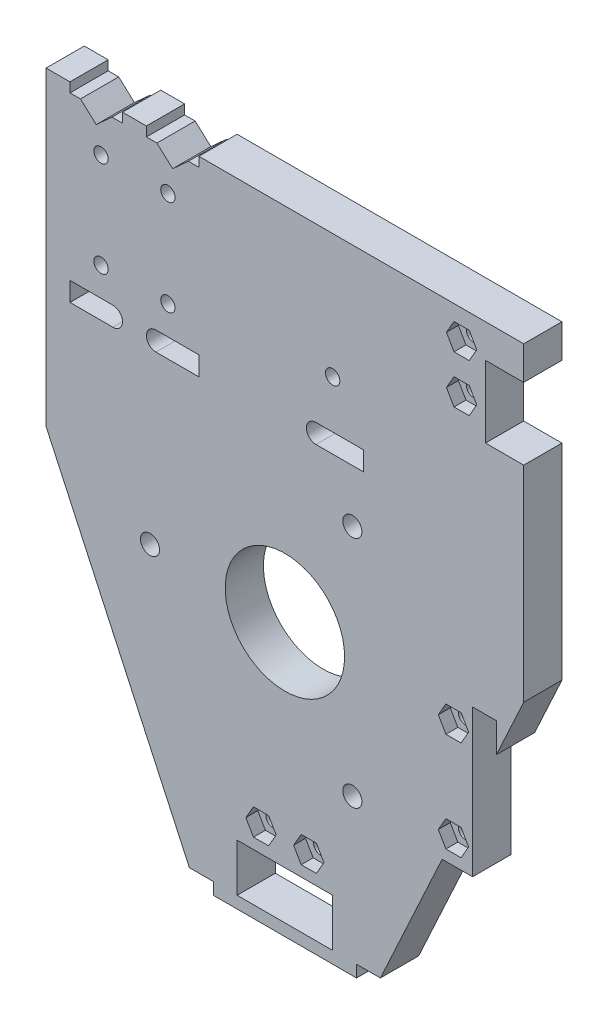
from build123d import *

# Parameters (mm, degrees)
SKETCH_1_W          = 100
SKETCH_1_H          = 130
EXTRUDE_1_DEPTH     = 8
SKETCH_3_W          = 20
SKETCH_3_H          = 10
CUT_EXTRUDE_1_DEPTH = 8
SKETCH_4_R          = 1.5
SKETCH_4_W          = 8
SKETCH_4_H          = 15
CUT_EXTRUDE_2_DEPTH = 9
CUT_EXTRUDE_6_DEPTH = 2.5
SKETCH_10_R         = 12.5
SKETCH_10_W         = 5
SKETCH_10_H         = 30.8
CUT_EXTRUDE_7_DEPTH = 9
EXTRUDE_3_DEPTH     = 8
SKETCH_5_R          = 2
SKETCH_5_R_2        = 1.5
CUT_EXTRUDE_3_DEPTH = 9
SKETCH_11_W         = 30
SKETCH_11_H         = 2.5
EXTRUDE_2_DEPTH     = 8
CUT_EXTRUDE_8_DEPTH = 2.5


with BuildPart() as part:
    # 草图1 → 凸台-拉伸1 (new body)
    with BuildSketch(Plane.XY):
        with Locations((50, 65)):
            Rectangle(SKETCH_1_W, SKETCH_1_H)
    extrude(amount=EXTRUDE_1_DEPTH)

    # 草图3 → 切除-拉伸1 (cut)
    with BuildSketch(Plane.XY.offset(8)):
        with Locations((50, 5)):
            Rectangle(SKETCH_3_W, SKETCH_3_H)
        Polygon((0, 0), (30, 0), (0, 65), align=None)
        Polygon((100, 0), (100, 65), (70, 0), align=None)
    extrude(amount=-CUT_EXTRUDE_1_DEPTH, mode=Mode.SUBTRACT)

    # 草图4 → 切除-拉伸2 (cut, through all)
    with BuildSketch(Plane(origin=(0, 0, 0), x_dir=(-1, 0, 0), z_dir=(0, 0, -1))):
        with Locations((-87, 124)):
            Circle(SKETCH_4_R)
        with Locations((-25.5, 100)):
            Circle(SKETCH_4_R)
        with Locations((-11.5, 100)):
            Circle(SKETCH_4_R)
        with Locations((-11.5, 120)):
            Circle(SKETCH_4_R)
        with Locations((-25.5, 120)):
            Circle(SKETCH_4_R)
        with Locations((-60, 104)):
            Circle(SKETCH_4_R)
        with Locations((-45, 15)):
            Circle(SKETCH_4_R)
        with Locations((-55, 15)):
            Circle(SKETCH_4_R)
        with Locations((-87, 114)):
            Circle(SKETCH_4_R)
        with BuildLine():
            Line((-56.5, 94), (-66.5, 94))
            Line((-66.5, 94), (-66.5, 90))
            Line((-66.5, 90), (-56.5, 90))
            ThreePointArc((-56.5, 90), (-54.5, 92), (-56.5, 94))
        make_face()
        with Locations((-96, 115.5)):
            Rectangle(SKETCH_4_W, SKETCH_4_H)
        with BuildLine():
            Line((-32, 94), (-32, 90))
            Line((-32, 90), (-23, 90))
            ThreePointArc((-23, 90), (-21, 92), (-23, 94))
            Line((-23, 94), (-32, 94))
        make_face()
        with BuildLine():
            Line((-5, 94), (-5, 90))
            Line((-5, 90), (-14, 90))
            ThreePointArc((-14, 90), (-16, 92), (-14, 94))
            Line((-14, 94), (-5, 94))
        make_face()
        Polygon((-10.5, 125), (-13.8, 128), (-16, 128), (-16, 130), (-5, 130), (-5, 128), (-7.2, 128), align=None)
        Polygon((-26.5, 125), (-29.8, 128), (-32, 128), (-32, 130), (-21, 130), (-21, 128), (-23.2, 128), align=None)
    extrude(amount=-CUT_EXTRUDE_2_DEPTH, mode=Mode.SUBTRACT)

    # 草图9 → 切除-拉伸6 (cut)
    with BuildSketch(Plane.XY.offset(8)):
        Polygon((90.175426481, 124), (88.58771324, 126.75), (85.41228676, 126.75), (83.824573519, 124), (85.41228676, 121.25), (88.58771324, 121.25), align=None)
        Polygon((90.175426481, 114), (88.58771324, 116.75), (85.41228676, 116.75), (83.824573519, 114), (85.41228676, 111.25), (88.58771324, 111.25), align=None)
        Polygon((48.175426481, 15), (46.58771324, 17.75), (43.41228676, 17.75), (41.824573519, 15), (43.41228676, 12.25), (46.58771324, 12.25), align=None)
        Polygon((58.175426481, 15), (56.58771324, 17.75), (53.41228676, 17.75), (51.824573519, 15), (53.41228676, 12.25), (56.58771324, 12.25), align=None)
    extrude(amount=-CUT_EXTRUDE_6_DEPTH, mode=Mode.SUBTRACT)

    # 草图10 → 切除-拉伸7 (cut, through all)
    with BuildSketch(Plane.XY.offset(8)):
        with Locations((50, 54.5)):
            Circle(SKETCH_10_R)
        with Locations((91.8, 43.4)):
            Rectangle(SKETCH_10_W, SKETCH_10_H)
    extrude(amount=-CUT_EXTRUDE_7_DEPTH, mode=Mode.SUBTRACT)

    # 草图12 → 凸台-拉伸3 (add)
    with BuildSketch(Plane.XY.offset(8)):
        Polygon((89.3, 41.816666667), (82.923076923, 28), (89.3, 28), align=None)
    extrude(amount=-EXTRUDE_3_DEPTH)

    # 草图5 → 切除-拉伸3 (cut, through all)
    with BuildSketch(Plane.XY.offset(8)):
        with Locations((21.75, 54.5)):
            Circle(SKETCH_5_R)
        with Locations((64.125, 78.965217657)):
            Circle(SKETCH_5_R)
        with Locations((64.125, 30.034782343)):
            Circle(SKETCH_5_R)
        with Locations((85.3, 53.8)):
            Circle(SKETCH_5_R_2)
        with Locations((85.3, 33)):
            Circle(SKETCH_5_R_2)
    extrude(amount=-CUT_EXTRUDE_3_DEPTH, mode=Mode.SUBTRACT)

    # 草图11 → 凸台-拉伸2 (add)
    with BuildSketch(Plane.XY.offset(8)):
        with Locations((50, -1.25)):
            Rectangle(SKETCH_11_W, SKETCH_11_H)
    extrude(amount=-EXTRUDE_2_DEPTH)

    # 草图14 → 切除-拉伸8 (cut)
    with BuildSketch(Plane.XY.offset(8)):
        Polygon((88.475426481, 53.8), (86.88771324, 56.55), (83.71228676, 56.55), (82.124573519, 53.8), (83.71228676, 51.05), (86.88771324, 51.05), align=None)
        Polygon((88.475426481, 33), (86.88771324, 35.75), (83.71228676, 35.75), (82.124573519, 33), (83.71228676, 30.25), (86.88771324, 30.25), align=None)
    extrude(amount=-CUT_EXTRUDE_8_DEPTH, mode=Mode.SUBTRACT)


solid = part.part
